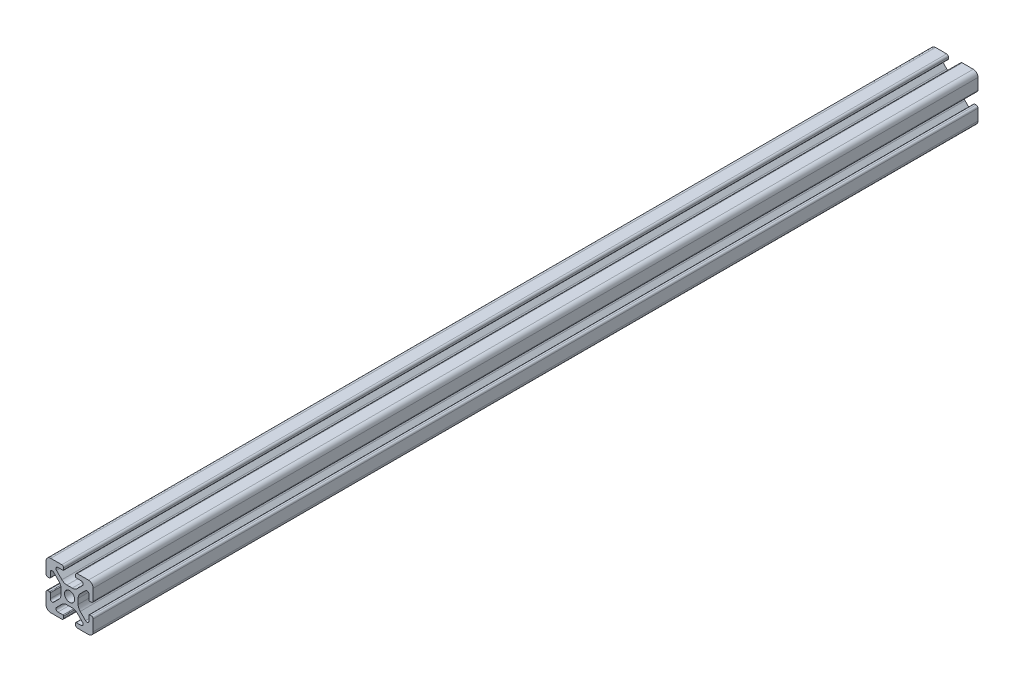
from build123d import *

# Parameters (mm, degrees)
SKETCH1_R           = 2.1463
BOSS_EXTRUDE1_DEPTH = 187.5


with BuildPart() as part:
    # Sketch1 → Boss-Extrude1 (new body, symmetric)
    with BuildSketch(Plane.XY):
        with BuildLine():
            Line((-9.9949, 7.9883), (-9.9949, 3.2893))
            ThreePointArc((-9.9949, 3.2893), (-9.76427588, 2.73252412), (-9.2075, 2.5019))
            Line((-9.2075, 2.5019), (-8.4963, 2.5019))
            ThreePointArc((-8.4963, 2.5019), (-8.280773853, 2.591173853), (-8.1915, 2.8067))
            Line((-8.1915, 2.8067), (-8.1915, 4.9149))
            ThreePointArc((-8.1915, 4.9149), (-7.674065253, 5.689295824), (-6.760603096, 5.507596904))
            Line((-6.760603096, 5.507596904), (-4.505765747, 3.252759555))
            ThreePointArc((-4.505765747, 3.252759555), (-3.856054457, 2.280397894), (-3.627906192, 1.133419111))
            Line((-3.627906192, 1.133419111), (-3.627906192, -1.133419111))
            ThreePointArc((-3.627906192, -1.133419111), (-3.856054457, -2.280397894), (-4.505765747, -3.252759555))
            Line((-4.505765747, -3.252759555), (-6.760603096, -5.507596904))
            ThreePointArc((-6.760603096, -5.507596904), (-7.674065253, -5.689295824), (-8.1915, -4.9149))
            Line((-8.1915, -4.9149), (-8.1915, -2.8067))
            ThreePointArc((-8.1915, -2.8067), (-8.280773853, -2.591173853), (-8.4963, -2.5019))
            Line((-8.4963, -2.5019), (-9.2075, -2.5019))
            ThreePointArc((-9.2075, -2.5019), (-9.76427588, -2.73252412), (-9.9949, -3.2893))
            Line((-9.9949, -3.2893), (-9.9949, -7.9883))
            ThreePointArc((-9.9949, -7.9883), (-9.407180467, -9.407180467), (-7.9883, -9.9949))
            Line((-7.9883, -9.9949), (-3.2893, -9.9949))
            ThreePointArc((-3.2893, -9.9949), (-2.73252412, -9.76427588), (-2.5019, -9.2075))
            Line((-2.5019, -9.2075), (-2.5019, -8.4963))
            ThreePointArc((-2.5019, -8.4963), (-2.591173853, -8.280773853), (-2.8067, -8.1915))
            Line((-2.8067, -8.1915), (-4.9149, -8.1915))
            ThreePointArc((-4.9149, -8.1915), (-5.689295824, -7.674065253), (-5.507596904, -6.760603096))
            Line((-5.507596904, -6.760603096), (-3.252759555, -4.505765747))
            ThreePointArc((-3.252759555, -4.505765747), (-2.280397894, -3.856054457), (-1.133419111, -3.627906192))
            Line((-1.133419111, -3.627906192), (1.133419111, -3.627906192))
            ThreePointArc((1.133419111, -3.627906192), (2.280397894, -3.856054457), (3.252759555, -4.505765747))
            Line((3.252759555, -4.505765747), (5.507596904, -6.760603096))
            ThreePointArc((5.507596904, -6.760603096), (5.689295824, -7.674065253), (4.9149, -8.1915))
            Line((4.9149, -8.1915), (2.8067, -8.1915))
            ThreePointArc((2.8067, -8.1915), (2.591173853, -8.280773853), (2.5019, -8.4963))
            Line((2.5019, -8.4963), (2.5019, -9.2075))
            ThreePointArc((2.5019, -9.2075), (2.73252412, -9.76427588), (3.2893, -9.9949))
            Line((3.2893, -9.9949), (7.9883, -9.9949))
            ThreePointArc((7.9883, -9.9949), (9.407180467, -9.407180467), (9.9949, -7.9883))
            Line((9.9949, -7.9883), (9.9949, -3.2893))
            ThreePointArc((9.9949, -3.2893), (9.76427588, -2.73252412), (9.2075, -2.5019))
            Line((9.2075, -2.5019), (8.4963, -2.5019))
            ThreePointArc((8.4963, -2.5019), (8.280773853, -2.591173853), (8.1915, -2.8067))
            Line((8.1915, -2.8067), (8.1915, -4.9149))
            ThreePointArc((8.1915, -4.9149), (7.674065253, -5.689295824), (6.760603096, -5.507596904))
            Line((6.760603096, -5.507596904), (4.505765747, -3.252759555))
            ThreePointArc((4.505765747, -3.252759555), (3.856054457, -2.280397894), (3.627906192, -1.133419111))
            Line((3.627906192, -1.133419111), (3.627906192, 1.133419111))
            ThreePointArc((3.627906192, 1.133419111), (3.856054457, 2.280397894), (4.505765747, 3.252759555))
            Line((4.505765747, 3.252759555), (6.760603096, 5.507596904))
            ThreePointArc((6.760603096, 5.507596904), (7.674065253, 5.689295824), (8.1915, 4.9149))
            Line((8.1915, 4.9149), (8.1915, 2.8067))
            ThreePointArc((8.1915, 2.8067), (8.280773853, 2.591173853), (8.4963, 2.5019))
            Line((8.4963, 2.5019), (9.2075, 2.5019))
            ThreePointArc((9.2075, 2.5019), (9.76427588, 2.73252412), (9.9949, 3.2893))
            Line((9.9949, 3.2893), (9.9949, 7.9883))
            ThreePointArc((9.9949, 7.9883), (9.407180467, 9.407180467), (7.9883, 9.9949))
            Line((7.9883, 9.9949), (3.2893, 9.9949))
            ThreePointArc((3.2893, 9.9949), (2.73252412, 9.76427588), (2.5019, 9.2075))
            Line((2.5019, 9.2075), (2.5019, 8.4963))
            ThreePointArc((2.5019, 8.4963), (2.591173853, 8.280773853), (2.8067, 8.1915))
            Line((2.8067, 8.1915), (4.9149, 8.1915))
            ThreePointArc((4.9149, 8.1915), (5.689295824, 7.674065253), (5.507596904, 6.760603096))
            Line((5.507596904, 6.760603096), (3.252759555, 4.505765747))
            ThreePointArc((3.252759555, 4.505765747), (2.280397894, 3.856054457), (1.133419111, 3.627906192))
            Line((1.133419111, 3.627906192), (-1.133419111, 3.627906192))
            ThreePointArc((-1.133419111, 3.627906192), (-2.280397894, 3.856054457), (-3.252759555, 4.505765747))
            Line((-3.252759555, 4.505765747), (-5.507596904, 6.760603096))
            ThreePointArc((-5.507596904, 6.760603096), (-5.689295824, 7.674065253), (-4.9149, 8.1915))
            Line((-4.9149, 8.1915), (-2.8067, 8.1915))
            ThreePointArc((-2.8067, 8.1915), (-2.591173853, 8.280773853), (-2.5019, 8.4963))
            Line((-2.5019, 8.4963), (-2.5019, 9.2075))
            ThreePointArc((-2.5019, 9.2075), (-2.73252412, 9.76427588), (-3.2893, 9.9949))
            Line((-3.2893, 9.9949), (-7.9883, 9.9949))
            ThreePointArc((-7.9883, 9.9949), (-9.407180467, 9.407180467), (-9.9949, 7.9883))
        make_face()
        Circle(SKETCH1_R, mode=Mode.SUBTRACT)
    extrude(amount=BOSS_EXTRUDE1_DEPTH, both=True)


solid = part.part
